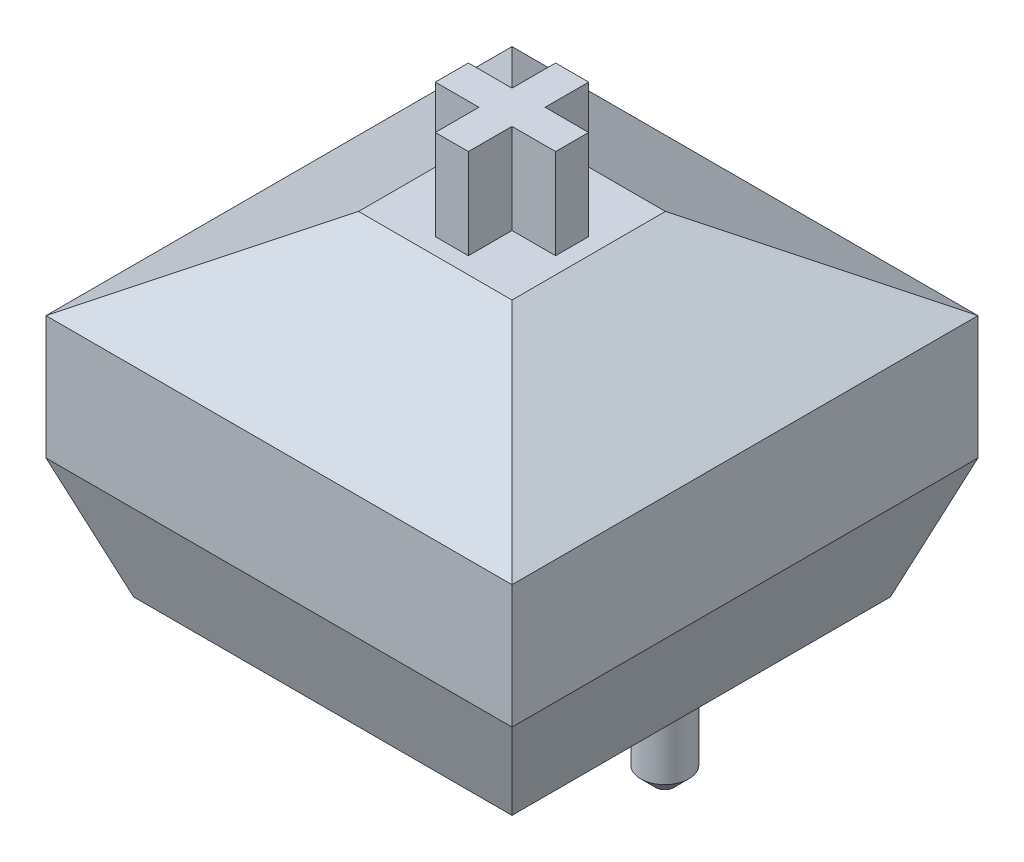
from build123d import *

# Parameters (mm, degrees)
SKETCH1_R             = 1.9
BOSS_EXTRUDE1_DEPTH   = 2.8
SKETCH1_R_2           = 0.8
BOSS_EXTRUDE1_2_DEPTH = 2.8
BOSS_EXTRUDE1_3_DEPTH = 2.8
SKETCH1_R_3           = 0.6
BOSS_EXTRUDE1_4_DEPTH = 2.8
BOSS_EXTRUDE1_5_DEPTH = 2.8
SKETCH2_W             = 15.494
SKETCH2_H             = 15.494
BOSS_EXTRUDE2_DEPTH   = 11.1
BOSS_EXTRUDE3_DEPTH   = 3
CHAMFER1_SIZE         = 3
CHAMFER1_SIZE2        = 5.196152423
CHAMFER1_PART_2_SIZE  = 3
CHAMFER1_PART_2_SIZE2 = 5.196152423
CHAMFER1_PART_3_SIZE  = 3
CHAMFER1_PART_3_SIZE2 = 5.196152423
CHAMFER1_PART_4_SIZE  = 3
CHAMFER1_PART_4_SIZE2 = 5.196152423
CHAMFER2_SIZE         = 4
CHAMFER2_SIZE2        = 1.455880937
CHAMFER2_PART_2_SIZE  = 4
CHAMFER2_PART_2_SIZE2 = 1.455880937
CHAMFER2_PART_3_SIZE  = 4
CHAMFER2_PART_3_SIZE2 = 1.455880937
CHAMFER2_PART_4_SIZE  = 4
CHAMFER2_PART_4_SIZE2 = 1.455880937
CHAMFER3_SIZE         = 0.5


with BuildPart() as part:
    # Sketch1 → Boss-Extrude1 (new body)
    with BuildSketch(Plane(origin=(0, 0, 0), x_dir=(1, 0, 0), z_dir=(0, 1, 0))):
        Circle(SKETCH1_R)
    extrude(amount=-BOSS_EXTRUDE1_DEPTH)



with BuildPart() as body_2:
    # Sketch1 → Boss-Extrude1 2 (new body)
    with BuildSketch(Plane(origin=(0, 0, 0), x_dir=(1, 0, 0), z_dir=(0, 1, 0))):
        with Locations((5.08, 0)):
            Circle(SKETCH1_R_2)
    extrude(amount=-BOSS_EXTRUDE1_2_DEPTH)


with BuildPart() as body_3:
    # Sketch1 → Boss-Extrude1 3 (new body)
    with BuildSketch(Plane(origin=(0, 0, 0), x_dir=(1, 0, 0), z_dir=(0, 1, 0))):
        with Locations((-5.08, 0)):
            Circle(SKETCH1_R_2)
    extrude(amount=-BOSS_EXTRUDE1_3_DEPTH)


with BuildPart() as body_4:
    # Sketch1 → Boss-Extrude1 4 (new body)
    with BuildSketch(Plane(origin=(0, 0, 0), x_dir=(1, 0, 0), z_dir=(0, 1, 0))):
        with Locations((-3.81, 2.54)):
            Circle(SKETCH1_R_3)
    extrude(amount=-BOSS_EXTRUDE1_4_DEPTH)


with BuildPart() as body_5:
    # Sketch1 → Boss-Extrude1 5 (new body)
    with BuildSketch(Plane(origin=(0, 0, 0), x_dir=(1, 0, 0), z_dir=(0, 1, 0))):
        with Locations((2.54, 5.08)):
            Circle(SKETCH1_R_3)
    extrude(amount=-BOSS_EXTRUDE1_5_DEPTH)


with BuildPart() as part_1:
    add(part.part)

    add(body_2.part)  # Boss-Extrude2 merges body 2

    add(body_3.part)  # Boss-Extrude2 merges body 3

    add(body_4.part)  # Boss-Extrude2 merges body 4

    add(body_5.part)  # Boss-Extrude2 merges body 5
    # Sketch2 → Boss-Extrude2 (add)
    with BuildSketch(Plane(origin=(0, 0, 0), x_dir=(1, 0, 0), z_dir=(0, 1, 0))):
        Rectangle(SKETCH2_W, SKETCH2_H)
    extrude(amount=BOSS_EXTRUDE2_DEPTH)

    # Sketch3 → Boss-Extrude3 (add)
    with BuildSketch(Plane(origin=(0, 11.1, 0), x_dir=(-1, 0, 0), z_dir=(0, 1, 0))):
        Polygon((0.55, -2), (-0.55, -2), (-0.55, -0.55), (-2, -0.55), (-2, 0.55), (-0.55, 0.55), (-0.55, 2), (0.55, 2), (0.55, 0.55), (2, 0.55), (2, -0.55), (0.55, -0.55), align=None)
    extrude(amount=BOSS_EXTRUDE3_DEPTH)

    # Chamfer1
    chamfer1_edges = [part_1.edges().sort_by_distance(p)[0] for p in [
        (-7.747, 11.1, 0),
    ]]
    chamfer1_side = [part_1.faces().sort_by_distance(p)[0] for p in [
        (-7.747, 5.55, 0),
    ]]
    chamfer(chamfer1_edges, length=CHAMFER1_SIZE, length2=CHAMFER1_SIZE2, reference=chamfer1_side[0])

    # Chamfer1 part 2
    chamfer1_part_2_edges = [part_1.edges().sort_by_distance(p)[0] for p in [
        (0, 11.1, 7.747),
    ]]
    chamfer1_part_2_side = [part_1.faces().sort_by_distance(p)[0] for p in [
        (0, 5.55, 7.747),
    ]]
    chamfer(chamfer1_part_2_edges, length=CHAMFER1_PART_2_SIZE, length2=CHAMFER1_PART_2_SIZE2, reference=chamfer1_part_2_side[0])

    # Chamfer1 part 3
    chamfer1_part_3_edges = [part_1.edges().sort_by_distance(p)[0] for p in [
        (7.747, 11.1, 0),
    ]]
    chamfer1_part_3_side = [part_1.faces().sort_by_distance(p)[0] for p in [
        (7.747, 5.55, 0),
    ]]
    chamfer(chamfer1_part_3_edges, length=CHAMFER1_PART_3_SIZE, length2=CHAMFER1_PART_3_SIZE2, reference=chamfer1_part_3_side[0])

    # Chamfer1 part 4
    chamfer1_part_4_edges = [part_1.edges().sort_by_distance(p)[0] for p in [
        (0, 11.1, -7.747),
    ]]
    chamfer1_part_4_side = [part_1.faces().sort_by_distance(p)[0] for p in [
        (0, 5.55, -7.747),
    ]]
    chamfer(chamfer1_part_4_edges, length=CHAMFER1_PART_4_SIZE, length2=CHAMFER1_PART_4_SIZE2, reference=chamfer1_part_4_side[0])

    # Chamfer2
    chamfer2_edges = [part_1.edges().sort_by_distance(p)[0] for p in [
        (-7.747, 0, 0),
    ]]
    chamfer2_side = [part_1.faces().sort_by_distance(p)[0] for p in [
        (-7.747, 4.05, 0),
    ]]
    chamfer(chamfer2_edges, length=CHAMFER2_SIZE, length2=CHAMFER2_SIZE2, reference=chamfer2_side[0])

    # Chamfer2 part 2
    chamfer2_part_2_edges = [part_1.edges().sort_by_distance(p)[0] for p in [
        (0, 0, 7.747),
    ]]
    chamfer2_part_2_side = [part_1.faces().sort_by_distance(p)[0] for p in [
        (0, 4.05, 7.747),
    ]]
    chamfer(chamfer2_part_2_edges, length=CHAMFER2_PART_2_SIZE, length2=CHAMFER2_PART_2_SIZE2, reference=chamfer2_part_2_side[0])

    # Chamfer2 part 3
    chamfer2_part_3_edges = [part_1.edges().sort_by_distance(p)[0] for p in [
        (7.747, 0, 0),
    ]]
    chamfer2_part_3_side = [part_1.faces().sort_by_distance(p)[0] for p in [
        (7.747, 4.05, 0),
    ]]
    chamfer(chamfer2_part_3_edges, length=CHAMFER2_PART_3_SIZE, length2=CHAMFER2_PART_3_SIZE2, reference=chamfer2_part_3_side[0])

    # Chamfer2 part 4
    chamfer2_part_4_edges = [part_1.edges().sort_by_distance(p)[0] for p in [
        (0, 0, -7.747),
    ]]
    chamfer2_part_4_side = [part_1.faces().sort_by_distance(p)[0] for p in [
        (0, 4.05, -7.747),
    ]]
    chamfer(chamfer2_part_4_edges, length=CHAMFER2_PART_4_SIZE, length2=CHAMFER2_PART_4_SIZE2, reference=chamfer2_part_4_side[0])

    # Chamfer3
    chamfer3_edges = [part_1.edges().sort_by_distance(p)[0] for p in [
        (4.28, -2.8, 0),
        (-5.88, -2.8, 0),
        (-1.9, -2.8, 0),
    ]]
    chamfer(chamfer3_edges, length=CHAMFER3_SIZE)


solid = part_1.part
